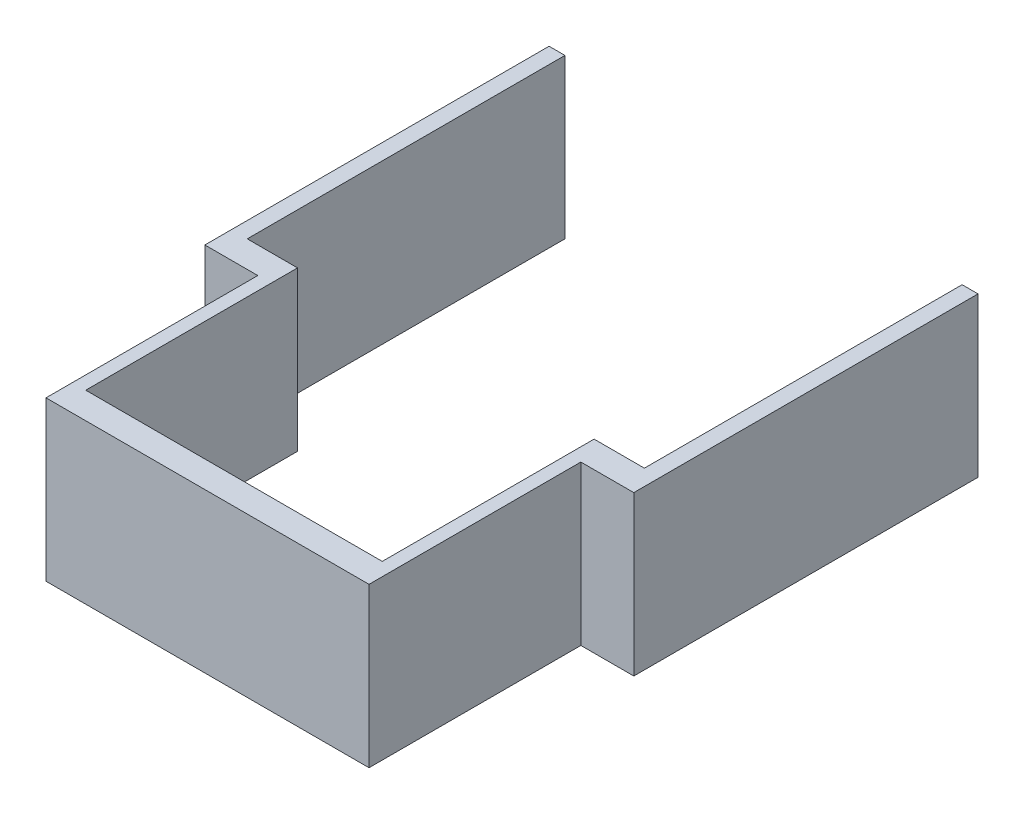
from build123d import *

# Parameters (mm, degrees)
ESQUISSE1_W             = 61
ESQUISSE1_H             = 30
BOSS_EXTRU_1_DEPTH      = 45
ESQUISSE2_W             = 56
ESQUISSE2_H             = 30
ENL_V_MAT_EXTRU_1_DEPTH = 40
ESQUISSE3_W             = 5
ESQUISSE3_H             = 30
BOSS_EXTRU_2_DEPTH      = 10
ESQUISSE4_W             = 5
ESQUISSE4_H             = 30
BOSS_EXTRU_3_DEPTH      = 10
ESQUISSE5_W             = 3
ESQUISSE5_H             = 30
BOSS_EXTRU_4_DEPTH      = 60
ESQUISSE6_W             = 3
ESQUISSE6_H             = 30
BOSS_EXTRU_5_DEPTH      = 60


with BuildPart() as part:
    # Esquisse1 → Boss.-Extru.1 (new body)
    with BuildSketch(Plane.XY):
        with Locations((-2.408366894, 0.644052045)):
            Rectangle(ESQUISSE1_W, ESQUISSE1_H)
    extrude(amount=BOSS_EXTRU_1_DEPTH)

    # Esquisse2 → Enlèv. mat.-Extru.1 (cut)
    with BuildSketch(Plane(origin=(0, 0, 0), x_dir=(-1, 0, 0), z_dir=(0, 0, -1))):
        with Locations((2.408366894, 0.644052045)):
            Rectangle(ESQUISSE2_W, ESQUISSE2_H)
    extrude(amount=-ENL_V_MAT_EXTRU_1_DEPTH, mode=Mode.SUBTRACT)

    # Esquisse3 → Boss.-Extru.2 (add)
    with BuildSketch(Plane(origin=(28.091633106, 0, 0), x_dir=(0, 0, -1), z_dir=(1, 0, 0))):
        with Locations((-2.5, 0.644052045)):
            Rectangle(ESQUISSE3_W, ESQUISSE3_H)
    extrude(amount=BOSS_EXTRU_2_DEPTH)

    # Esquisse4 → Boss.-Extru.3 (add)
    with BuildSketch(Plane.ZY.offset(32.908366894)):
        with Locations((2.5, 0.644052045)):
            Rectangle(ESQUISSE4_W, ESQUISSE4_H)
    extrude(amount=BOSS_EXTRU_3_DEPTH)

    # Esquisse5 → Boss.-Extru.4 (add)
    with BuildSketch(Plane(origin=(0, 0, 0), x_dir=(-1, 0, 0), z_dir=(0, 0, -1))):
        with Locations((-36.591633106, 0.644052045)):
            Rectangle(ESQUISSE5_W, ESQUISSE5_H)
    extrude(amount=BOSS_EXTRU_4_DEPTH)

    # Esquisse6 → Boss.-Extru.5 (add)
    with BuildSketch(Plane(origin=(0, 0, 0), x_dir=(-1, 0, 0), z_dir=(0, 0, -1))):
        with Locations((41.408366894, 0.644052045)):
            Rectangle(ESQUISSE6_W, ESQUISSE6_H)
    extrude(amount=BOSS_EXTRU_5_DEPTH)


solid = part.part
